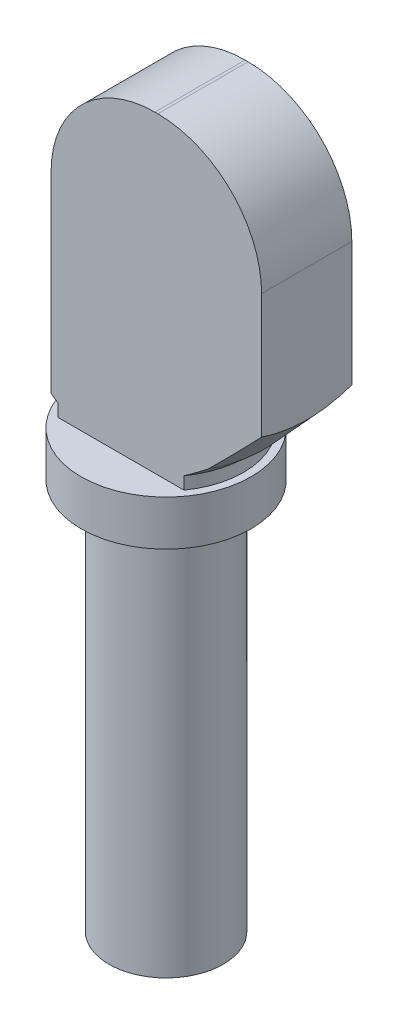
from build123d import *

# Parameters (mm, degrees)
BOSS_EXTRUDE1_DEPTH = 1.5


with BuildPart() as part:
    # Sketch1 → Revolve1 (revolve)
    with BuildSketch(Plane.XY):
        Polygon((0, 0), (1.9, 0), (1.9, 13), (2.825, 13), (2.825, 14.5), (0, 14.5), align=None)
    revolve(axis=Axis((0, 0, 0), (0, 1, 0)))

    # Sketch2 → Boss-Extrude1 (add, symmetric)
    with BuildSketch(Plane.XY):
        with BuildLine():
            Line((-2.325, 14.5), (-2.325, 21.45))
            ThreePointArc((-2.325, 21.45), (-1.314518395, 23.889518395), (1.125, 24.9))
            Line((1.125, 24.9), (1.225, 24.9))
            ThreePointArc((1.225, 24.9), (3.664518395, 23.889518395), (4.675, 21.45))
            Line((4.675, 21.45), (4.675, 15.5))
            Line((4.675, 15.5), (2.575, 15))
            Line((2.575, 15), (2.575, 14.5))
            Line((2.575, 14.5), (-2.325, 14.5))
        make_face()
    extrude(amount=BOSS_EXTRUDE1_DEPTH, both=True)

    # Sketch3 → DELETE CUT TO SEE REAL COMPONENT (revolve, cut)
    with BuildSketch(Plane.XY):
        Polygon((3.25, 15.5), (5.35, 17.8), (6.288787076, 17.8), (6.288787076, 14.5), (2.575, 14.5), (2.575, 14.913043478), align=None)
    revolve(axis=Axis((0, 0, 0), (0, 1, 0)), mode=Mode.SUBTRACT)


solid = part.part
